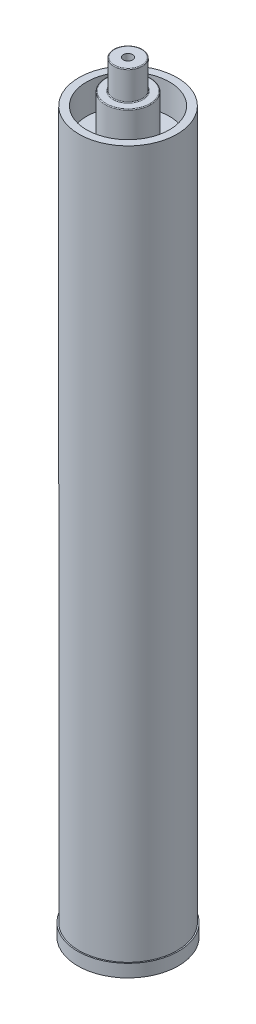
from build123d import *

# Parameters (mm, degrees)
SKETCH1_R           = 14.351
BOSS_EXTRUDE1_DEPTH = 29.2608
SKETCH2_R           = 22.6949
BOSS_EXTRUDE2_DEPTH = 42.9006
SKETCH3_R           = 49.2379
BOSS_EXTRUDE3_DEPTH = 679.704
SKETCH4_R           = 49.2379
SKETCH4_R_2         = 41.6179
BOSS_EXTRUDE4_DEPTH = 29.9212
SKETCH5_R           = 4.64185
CUT_EXTRUDE1_DEPTH  = 74.99858
SKETCH6_R           = 50.5079
BOSS_EXTRUDE5_DEPTH = 12.7
SKETCH9_R           = 38.900000051
SKETCH8_R           = 44.621320206
FILLET1_R           = 0.762


with BuildPart() as part:
    # Sketch1 → Boss-Extrude1 (new body)
    with BuildSketch(Plane(origin=(0, 0, 0), x_dir=(1, 0, 0), z_dir=(0, 1, 0))):
        Circle(SKETCH1_R)
    extrude(amount=-BOSS_EXTRUDE1_DEPTH)

    # Sketch2 → Boss-Extrude2 (add)
    with BuildSketch(Plane.XZ.offset(29.2608)):
        Circle(SKETCH2_R)
    extrude(amount=BOSS_EXTRUDE2_DEPTH)

    # Sketch3 → Boss-Extrude3 (add)
    with BuildSketch(Plane.XZ.offset(72.1614)):
        Circle(SKETCH3_R)
    extrude(amount=BOSS_EXTRUDE3_DEPTH)

    # Sketch4 → Boss-Extrude4 (add)
    with BuildSketch(Plane(origin=(0, -72.1614, 0), x_dir=(1, 0, 0), z_dir=(0, 1, 0))):
        Circle(SKETCH4_R)
        Circle(SKETCH4_R_2, mode=Mode.SUBTRACT)
    extrude(amount=BOSS_EXTRUDE4_DEPTH)

    # Sketch5 → Cut-Extrude1 (cut)
    with BuildSketch(Plane(origin=(0, 0, 0), x_dir=(1, 0, 0), z_dir=(0, 1, 0))):
        Circle(SKETCH5_R)
    extrude(amount=-CUT_EXTRUDE1_DEPTH, mode=Mode.SUBTRACT)

    # Sketch6 → Boss-Extrude5 (add)
    with BuildSketch(Plane.XZ.offset(751.8654)):
        Circle(SKETCH6_R)
    extrude(amount=BOSS_EXTRUDE5_DEPTH)

    # Sketch9 → Cut-Loft1 section 0
    with BuildSketch(Plane(origin=(0, -747.837378846, 0), x_dir=(-1, 0, 0), z_dir=(0, -1, 0))):
        Circle(SKETCH9_R)
    # Sketch8 → Cut-Loft1 section 1
    with BuildSketch(Plane.XZ.offset(764.5654)):
        Circle(SKETCH8_R)
    loft(mode=Mode.SUBTRACT)

    # Fillet1
    fillet1_edges = [part.edges().sort_by_distance(p)[0] for p in [
        (-14.351, 0, 0),
        (-14.351, -29.2608, 0),
        (-22.6949, -29.2608, 0),
        (-22.6949, -72.1614, 0),
    ]]
    fillet(fillet1_edges, radius=FILLET1_R)


solid = part.part
